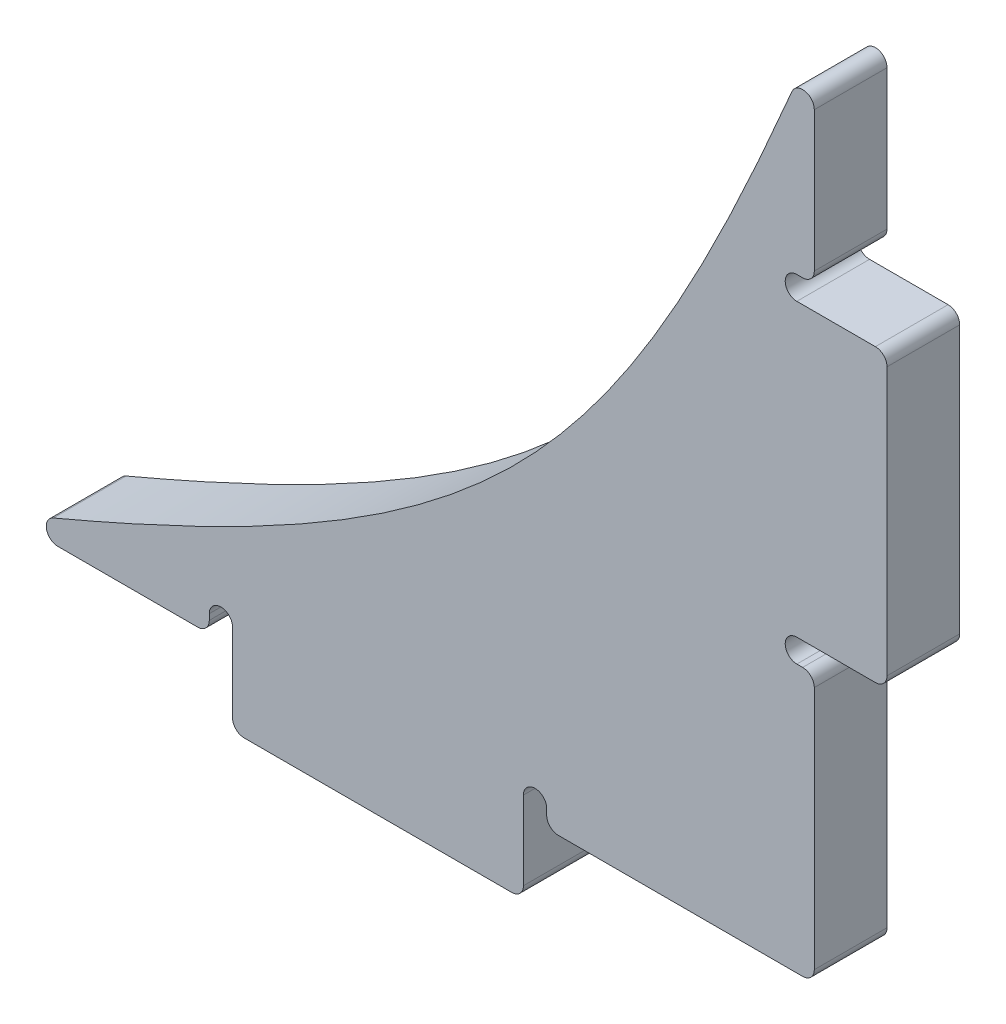
from build123d import *

# Parameters (mm, degrees)
BOSS_EXTRUDE1_DEPTH = 3.175
SKETCH2_W           = 12.7
SKETCH2_H           = 3.175
BOSS_EXTRUDE2_DEPTH = 3.175
SKETCH3_W           = 3.175
SKETCH3_H           = 12.7
BOSS_EXTRUDE3_DEPTH = 3.175
CUT_EXTRUDE1_REACH  = 5.175
FILLET1_R           = 0.508
SCALE1_SCALE        = 0.35


with BuildPart() as part:
    # Sketch1 → Boss-Extrude1 (new body)
    with BuildSketch(Plane.XY):
        with BuildLine():
            Line((22.86, -12.7), (-12.7, -12.7))
            add(Edge.make_bspline(
                [(22.86, 22.86), (14.060256121, 1.487897552), (8.672102448, -3.900256121), (-12.7, -12.7)],
                knots=[0, 0, 0, 0, 1, 1, 1, 1], degree=3))
            Line((22.86, 22.86), (22.86, -12.7))
        make_face()
    extrude(amount=BOSS_EXTRUDE1_DEPTH)

    # Sketch2 → Boss-Extrude2 (add)
    with BuildSketch(Plane.XZ.offset(12.7)):
        with Locations((3.81, 1.5875)):
            Rectangle(SKETCH2_W, SKETCH2_H)
    extrude(amount=BOSS_EXTRUDE2_DEPTH)

    # Sketch3 → Boss-Extrude3 (add)
    with BuildSketch(Plane(origin=(22.86, 0, 0), x_dir=(0, 0, -1), z_dir=(1, 0, 0))):
        with Locations((-1.5875, 6.35)):
            Rectangle(SKETCH3_W, SKETCH3_H)
    extrude(amount=BOSS_EXTRUDE3_DEPTH)

    # Sketch4 → Cut-Extrude1 (cut, up to next)
    with BuildSketch(Plane.XY.offset(3.175), mode=Mode.PRIVATE) as cut_extrude1_sk1:
        with BuildLine():
            Line((-3.556, -11.938), (-3.556, -12.7))
            Line((-3.556, -12.7), (-2.54, -12.7))
            Line((-2.54, -12.7), (-2.54, -11.938))
            ThreePointArc((-2.54, -11.938), (-3.048, -11.43), (-3.556, -11.938))
        make_face()
    cut_extrude1_tool1 = extrude(cut_extrude1_sk1.sketch, amount=-CUT_EXTRUDE1_REACH, mode=Mode.PRIVATE) & part.part
    add(cut_extrude1_tool1.solids().sort_by_distance((-3.048, -12.113972, 3.175))[0], mode=Mode.SUBTRACT)
    # Sketch4 → Cut-Extrude1 (cut, up to next)
    with BuildSketch(Plane.XY.offset(3.175), mode=Mode.PRIVATE) as cut_extrude1_sk2:
        with BuildLine():
            Line((10.16, -11.938), (10.16, -12.7))
            Line((10.16, -12.7), (11.176, -12.7))
            Line((11.176, -12.7), (11.176, -11.938))
            ThreePointArc((11.176, -11.938), (10.668, -11.43), (10.16, -11.938))
        make_face()
    cut_extrude1_tool2 = extrude(cut_extrude1_sk2.sketch, amount=-CUT_EXTRUDE1_REACH, mode=Mode.PRIVATE) & part.part
    add(cut_extrude1_tool2.solids().sort_by_distance((10.668, -12.113972, 3.175))[0], mode=Mode.SUBTRACT)
    # Sketch4 → Cut-Extrude1 (cut, up to next)
    with BuildSketch(Plane.XY.offset(3.175), mode=Mode.PRIVATE) as cut_extrude1_sk3:
        with BuildLine():
            Line((22.098, -1.016), (22.86, -1.016))
            Line((22.86, -1.016), (22.86, 0))
            Line((22.86, 0), (22.098, 0))
            ThreePointArc((22.098, 0), (21.59, -0.508), (22.098, -1.016))
        make_face()
    cut_extrude1_tool3 = extrude(cut_extrude1_sk3.sketch, amount=-CUT_EXTRUDE1_REACH, mode=Mode.PRIVATE) & part.part
    add(cut_extrude1_tool3.solids().sort_by_distance((22.273972, -0.508, 3.175))[0], mode=Mode.SUBTRACT)
    # Sketch4 → Cut-Extrude1 (cut, up to next)
    with BuildSketch(Plane.XY.offset(3.175), mode=Mode.PRIVATE) as cut_extrude1_sk4:
        with BuildLine():
            Line((22.098, 12.7), (22.86, 12.7))
            Line((22.86, 12.7), (22.86, 13.716))
            Line((22.86, 13.716), (22.098, 13.716))
            ThreePointArc((22.098, 13.716), (21.59, 13.208), (22.098, 12.7))
        make_face()
    cut_extrude1_tool4 = extrude(cut_extrude1_sk4.sketch, amount=-CUT_EXTRUDE1_REACH, mode=Mode.PRIVATE) & part.part
    add(cut_extrude1_tool4.solids().sort_by_distance((22.273972, 13.208, 3.175))[0], mode=Mode.SUBTRACT)

    # Fillet1
    fillet1_edges = [part.edges().sort_by_distance(p)[0] for p in [
        (22.86, 13.716, 1.5875),
        (26.035, 12.7, 1.5875),
        (26.035, 0, 1.5875),
        (22.86, -1.016, 1.5875),
        (22.86, -12.7, 1.5875),
        (11.176, -12.7, 1.5875),
        (10.16, -15.875, 1.5875),
        (-2.54, -15.875, 1.5875),
        (-3.556, -12.7, 1.5875),
        (-12.7, -12.7, 1.5875),
        (22.86, 22.86, 1.5875),
    ]]
    fillet(fillet1_edges, radius=FILLET1_R)


with BuildPart() as part_1:
    # Scale1: scaled about (13.259441719, -3.099441698, 1.5875)
    add(part.part.scale(SCALE1_SCALE).moved(Location((8.618637117, -2.014637104, 1.031875))))


solid = part_1.part
